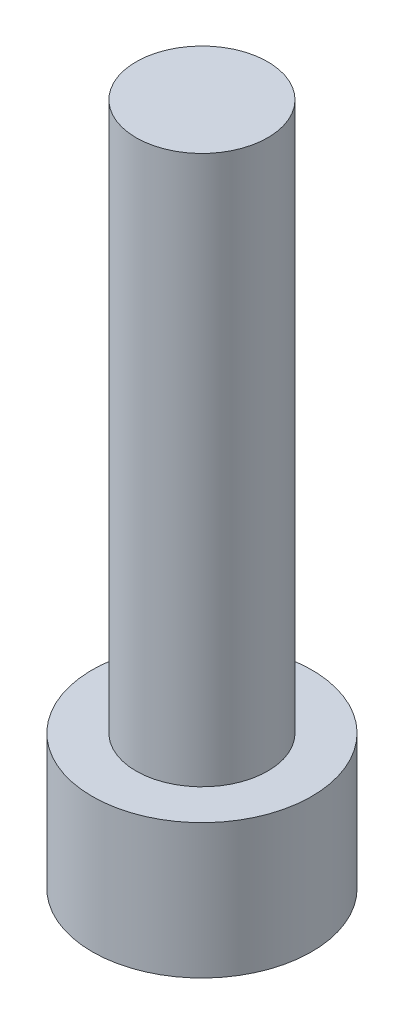
from build123d import *

# Parameters (mm, degrees)
SKETCH1_R           = 2.8575
BOSS_EXTRUDE1_DEPTH = 3.5052
CUT_EXTRUDE1_DEPTH  = 1.9558
SKETCH3_R           = 1.7145
BOSS_EXTRUDE2_DEPTH = 14.2875


with BuildPart() as part:
    # Sketch1 → Boss-Extrude1 (new body)
    with BuildSketch(Plane(origin=(0, 0, 0), x_dir=(1, 0, 0), z_dir=(0, 1, 0))):
        Circle(SKETCH1_R)
    extrude(amount=BOSS_EXTRUDE1_DEPTH)

    # Sketch2 → Cut-Extrude1 (cut)
    with BuildSketch(Plane.XZ):
        Polygon((1.603951217, 0), (0.801975608, 1.3890625), (-0.801975608, 1.3890625), (-1.603951217, 0), (-0.801975608, -1.3890625), (0.801975608, -1.3890625), align=None)
    extrude(amount=-CUT_EXTRUDE1_DEPTH, mode=Mode.SUBTRACT)

    # Sketch3 → Boss-Extrude2 (add)
    with BuildSketch(Plane(origin=(0, 3.5052, 0), x_dir=(1, 0, 0), z_dir=(0, 1, 0))):
        Circle(SKETCH3_R)
    extrude(amount=BOSS_EXTRUDE2_DEPTH)


solid = part.part
